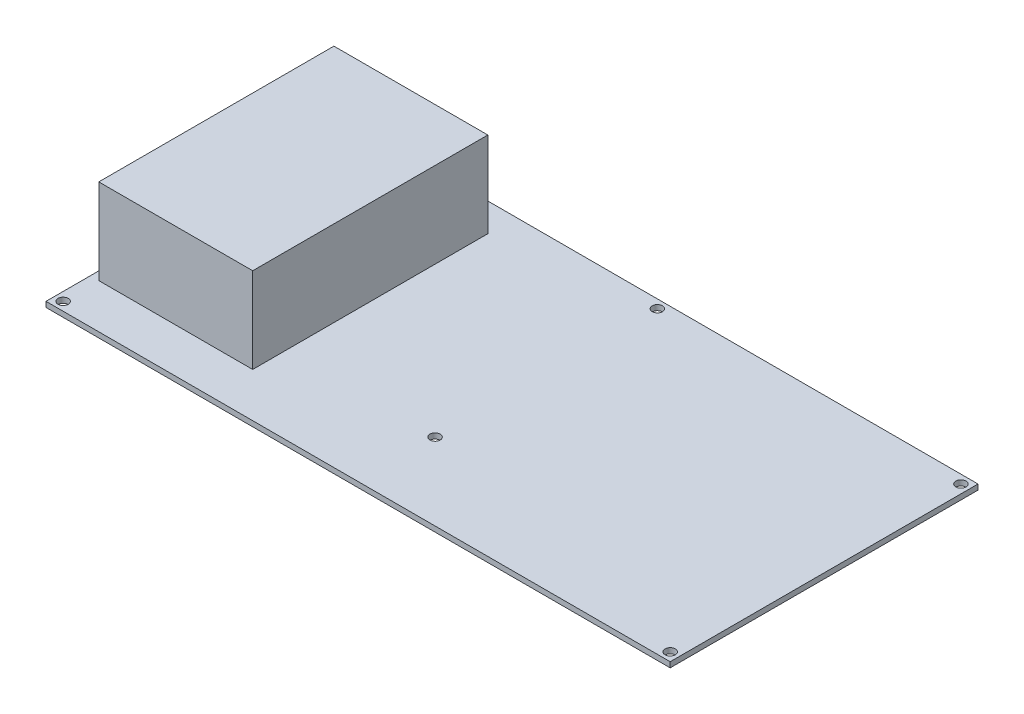
from build123d import *

# Parameters (mm, degrees)
SKETCH1_W           = 185.42
SKETCH1_H           = 91.44
SKETCH1_R           = 1.524
BOSS_EXTRUDE1_DEPTH = 1.5875
SKETCH2_W           = 45.72
SKETCH2_H           = 69.85
BOSS_EXTRUDE2_DEPTH = 25.4


with BuildPart() as part:
    # Sketch1 → Boss-Extrude1 (new body)
    with BuildSketch(Plane(origin=(0, 0, 0), x_dir=(1, 0, 0), z_dir=(0, 1, 0))):
        with Locations((-3.360446214, 2.811906005)):
            Rectangle(SKETCH1_W, SKETCH1_H)
        with Locations((-93.530446214, 45.991906005)):
            Circle(SKETCH1_R, mode=Mode.SUBTRACT)
        with Locations((86.809553786, 45.991906005)):
            Circle(SKETCH1_R, mode=Mode.SUBTRACT)
        with Locations((86.809553786, -40.368093995)):
            Circle(SKETCH1_R, mode=Mode.SUBTRACT)
        with Locations((-93.530446214, -40.368093995)):
            Circle(SKETCH1_R, mode=Mode.SUBTRACT)
        with Locations((-3.360446214, 45.991906005)):
            Circle(SKETCH1_R, mode=Mode.SUBTRACT)
        with Locations((-3.360446214, -20.048093995)):
            Circle(SKETCH1_R, mode=Mode.SUBTRACT)
    extrude(amount=BOSS_EXTRUDE1_DEPTH)

    # Sketch2 → Boss-Extrude2 (add)
    with BuildSketch(Plane(origin=(0, 1.5875, 0), x_dir=(1, 0, 0), z_dir=(0, 1, 0))):
        with Locations((-70.702750799, 5.188938255)):
            Rectangle(SKETCH2_W, SKETCH2_H)
    extrude(amount=BOSS_EXTRUDE2_DEPTH)


solid = part.part
